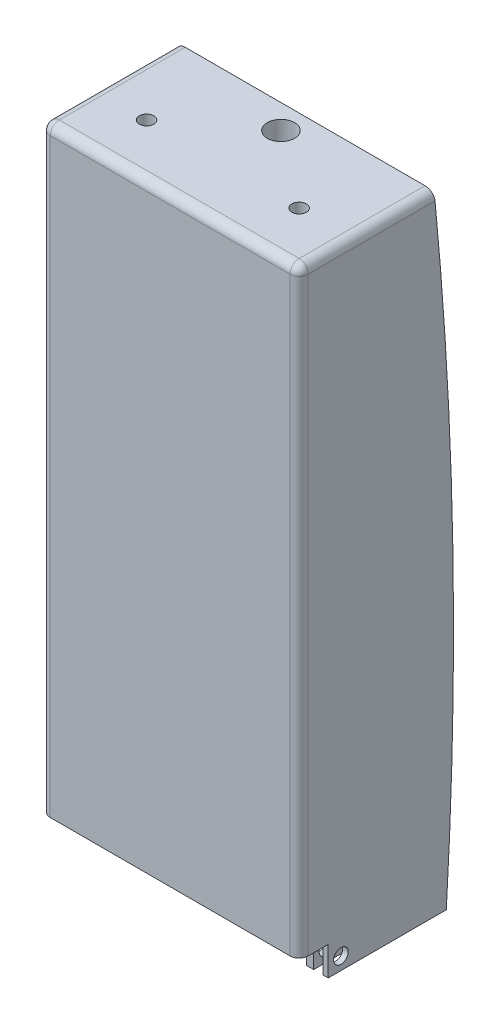
from build123d import *

# Parameters (mm, degrees)
CUT_EXTRUDE1_DEPTH      = 10
CUT_EXTRUDE1_DEPTH_BACK = 10
SKETCH7_W               = 161.67088451347962
SKETCH7_H               = 99.40268669666085
SKETCH8_W               = 4.999999999999993
SKETCH8_H               = 94
CUT_EXTRUDE2_DEPTH      = 35
SKETCH9_R               = 7.5
SKETCH9_R_2             = 4.000000000000013
SKETCH9_R_3             = 4.000000000000005
CUT_EXTRUDE3_DEPTH      = 357.06460088023357
SKETCH10_R              = 4.000000000000005
CUT_EXTRUDE4_DEPTH      = 386.9080201291493
SKETCH11_W              = 141.9999999999999
SKETCH11_H              = 16
BOSS_EXTRUDE1_DEPTH     = 330
FILLET2_R               = 5
FILLET3_R               = 5
FILLET4_R               = 5
FILLET5_R               = 5
FILLET6_R               = 5
CUT_EXTRUDE5_DEPTH      = 389.0992141192763


with BuildPart() as part:
    # Sweep2: sweep along a path in Sketch4
    with BuildLine(Plane.XY) as sweep2_path:
        Line((-65, 350), (-64.99999999999994, 10.000000000000007))
        ThreePointArc((-64.99999999999994, 10.000000000000007), (-62.07106781186544, 2.928932188134527), (-54.99999999999996, 0))
        Line((-54.99999999999996, 0), (54.99999999999999, 0))
        ThreePointArc((54.99999999999999, 0), (62.071067811865476, 2.9289321881345227), (65, 10))
        Line((65, 10), (65, 350))
        Line((65, 350), (-65, 350))
    # Sketch6 → Sweep2 (sweep)
    with BuildSketch(Plane(origin=(0, 0, 0), x_dir=(0, 0, -1), z_dir=(1, 0, 0))):
        Polygon((45.00000000000006, 355.99999999999994), (-44.999999999999936, 355.99999999999994), (-44.999999999999936, 343.99999999999994), (45.000000000000064, 344), align=None)
    sweep(path=sweep2_path.line, transition=Transition.RIGHT)

    # Sketch7 → Cut-Extrude1 (cut, two sides: drawn at the far end of the back side and taken through both)
    with BuildSketch(Plane(origin=(0, 0, 0), x_dir=(1, 0, 0), z_dir=(0, 1, 0)).offset(-CUT_EXTRUDE1_DEPTH_BACK)):
        Rectangle(SKETCH7_W, SKETCH7_H)
    extrude(amount=CUT_EXTRUDE1_DEPTH + CUT_EXTRUDE1_DEPTH_BACK, mode=Mode.SUBTRACT)

    # Sketch8 → Cut-Extrude2 (cut)
    with BuildSketch(Plane(origin=(0, 0, 0), x_dir=(1, 0, 0), z_dir=(0, 1, 0))):
        with Locations((-65.5, 0.24224418482823395)):
            Rectangle(SKETCH8_W, SKETCH8_H)
        with Locations((65.5, 0.24224418482823395)):
            Rectangle(SKETCH8_W, SKETCH8_H)
    extrude(amount=CUT_EXTRUDE2_DEPTH, mode=Mode.SUBTRACT)

    # Sketch9 → Cut-Extrude3 (cut, through all)
    with BuildSketch(Plane(origin=(0, 355.99999999999994, 0), x_dir=(1, 0, 0), z_dir=(0, 1, 0))):
        with Locations(Location((0, 0, 0), (0, 0, 270))):
            Circle(SKETCH9_R)
        with Locations(Location((-42, 31.999999999999993, 0), (0, 0, 270))):
            Circle(SKETCH9_R_2)
        with Locations(Location((-42, -32.00000000000001, 0), (0, 0, 270))):
            Circle(SKETCH9_R_3)
        with Locations(Location((42, -31.999999999999954, 0), (0, 0, 90))):
            Circle(SKETCH9_R_3)
        with Locations(Location((42, 32, 0), (0, 0, 90))):
            Circle(SKETCH9_R_2)
    extrude(amount=-CUT_EXTRUDE3_DEPTH, mode=Mode.SUBTRACT)

    # Sketch10 → Cut-Extrude4 (cut, through all)
    with BuildSketch(Plane(origin=(70.99999999999996, 0, 0), x_dir=(0, 0, -1), z_dir=(1, 0, 0))):
        with Locations((-37.999999999999936, 17.000000000000014)):
            Circle(SKETCH10_R)
    extrude(amount=-CUT_EXTRUDE4_DEPTH, mode=Mode.SUBTRACT)

    # Sketch11 → Boss-Extrude1 (add)
    with BuildSketch(Plane(origin=(0, 355.99999999999994, 0), x_dir=(1, 0, 0), z_dir=(0, 1, 0))):
        with Locations((0, -52.999999999999936)):
            Rectangle(SKETCH11_W, SKETCH11_H)
    extrude(amount=-BOSS_EXTRUDE1_DEPTH)

    # Fillet2
    fillet2_edges = [part.edges().sort_by_distance(p)[0] for p in [
        (59.00000000000001, 177, -45.000000000000064),
    ]]
    fillet(fillet2_edges, radius=FILLET2_R)

    # Fillet3
    fillet3_edges = [part.edges().sort_by_distance(p)[0] for p in [
        (70.99999999999994, 182.99999999999997, -45.00000000000005),
    ]]
    fillet(fillet3_edges, radius=FILLET3_R)

    # Fillet4
    fillet4_edges = [part.edges().sort_by_distance(p)[0] for p in [
        (-59.00000000000001, 177, -45.000000000000064),
    ]]
    fillet(fillet4_edges, radius=FILLET4_R)

    # Fillet5
    fillet5_edges = [part.edges().sort_by_distance(p)[0] for p in [
        (-70.99999999999994, 182.99999999999997, -45.00000000000005),
    ]]
    fillet(fillet5_edges, radius=FILLET5_R)

    # Fillet6
    fillet6_edges = [part.edges().sort_by_distance(p)[0] for p in [
        (70.99999999999994, 355.99999999999994, 10.499999999999893),
        (69.53553390593268, 355.9999999999999, -43.535533905932894),
        (0, 355.99999999999994, -45.00000000000005),
        (0, 355.99999999999994, -45.00000000000005),
        (-69.53553390593268, 355.99999999999994, -43.535533905932795),
        (-70.99999999999994, 355.99999999999994, 10.499999999999936),
        (0, 355.99999999999994, 60.999999999999936),
        (-70.99999999999994, 190.99999999999994, 60.999999999999936),
        (70.99999999999994, 190.99999999999994, 60.999999999999936),
    ]]
    fillet(fillet6_edges, radius=FILLET6_R)

    # Sketch12 → Cut-Extrude5 (cut, through all)
    with BuildSketch(Plane.ZY.offset(70.9999999999999)):
        with BuildLine():
            Line((-19.99811023879916, 9.999999999999995), (-79.77303285275339, 10.000000000000018))
            Line((-79.77303285275339, 10.000000000000018), (-79.77303285275339, 406.4421165391139))
            Line((-79.77303285275339, 406.4421165391139), (-12.883579031367276, 360.2403098799698))
            ThreePointArc((-12.883579031367276, 360.2403098799698), (-23.51999666611846, 185.26395577223084), (-19.99811023879916, 9.999999999999995))
        make_face()
    extrude(amount=-CUT_EXTRUDE5_DEPTH, mode=Mode.SUBTRACT)


solid = part.part
